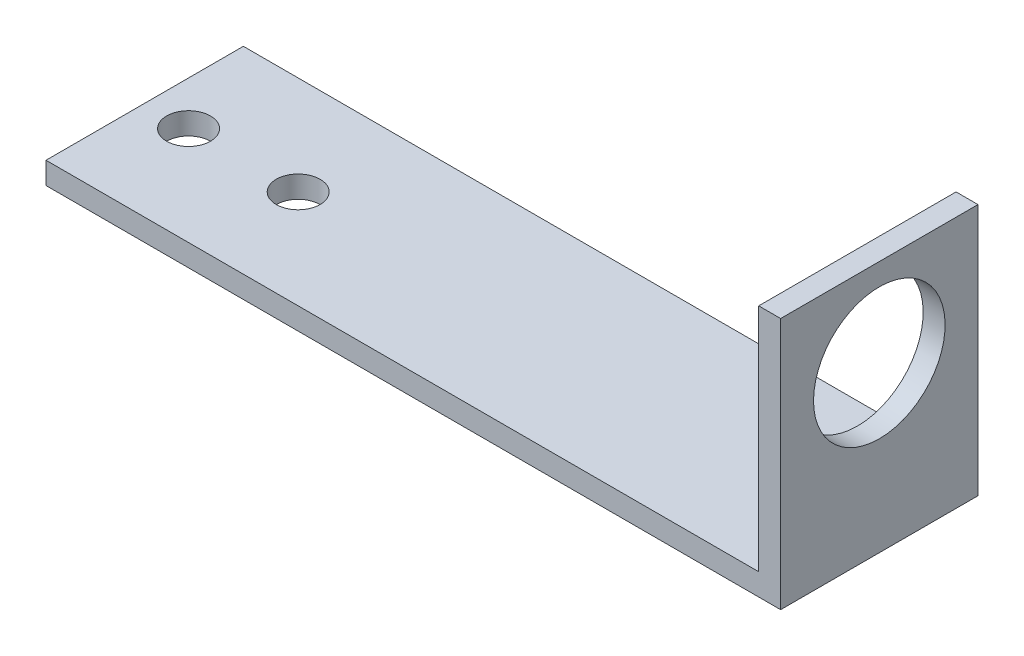
from build123d import *

# Parameters (mm, degrees)
BOSS_EXTRUDE1_DEPTH = 18
CUT_EXTRUDE1_REACH  = 4
SKETCH2_R           = 6
CUT_EXTRUDE2_REACH  = 4
SKETCH3_R           = 2


with BuildPart() as part:
    # Sketch1 → Boss-Extrude1 (new body)
    with BuildSketch(Plane.XY):
        Polygon((0, 0), (0, 23), (-2, 23), (-2, 2), (-67, 2), (-67, 0), align=None)
    extrude(amount=BOSS_EXTRUDE1_DEPTH)

    # Sketch2 → Cut-Extrude1 (cut, up to next)
    with BuildSketch(Plane.ZY.offset(2), mode=Mode.PRIVATE) as cut_extrude1_sk1:
        with Locations((9, 15)):
            Circle(SKETCH2_R)
    cut_extrude1_tool1 = extrude(cut_extrude1_sk1.sketch, amount=-CUT_EXTRUDE1_REACH, mode=Mode.PRIVATE) & part.part
    add(cut_extrude1_tool1.solids().sort_by_distance((-2, 15, 9))[0], mode=Mode.SUBTRACT)

    # Sketch3 → Cut-Extrude2 (cut, up to next)
    with BuildSketch(Plane(origin=(0, 2, 0), x_dir=(1, 0, 0), z_dir=(0, 1, 0)), mode=Mode.PRIVATE) as cut_extrude2_sk1:
        with Locations((-63, -9)):
            Circle(SKETCH3_R)
    cut_extrude2_tool1 = extrude(cut_extrude2_sk1.sketch, amount=-CUT_EXTRUDE2_REACH, mode=Mode.PRIVATE) & part.part
    add(cut_extrude2_tool1.solids().sort_by_distance((-63, 2, 9))[0], mode=Mode.SUBTRACT)
    # Sketch3 → Cut-Extrude2 (cut, up to next)
    with BuildSketch(Plane(origin=(0, 2, 0), x_dir=(1, 0, 0), z_dir=(0, 1, 0)), mode=Mode.PRIVATE) as cut_extrude2_sk2:
        with Locations((-53, -9)):
            Circle(SKETCH3_R)
    cut_extrude2_tool2 = extrude(cut_extrude2_sk2.sketch, amount=-CUT_EXTRUDE2_REACH, mode=Mode.PRIVATE) & part.part
    add(cut_extrude2_tool2.solids().sort_by_distance((-53, 2, 9))[0], mode=Mode.SUBTRACT)


solid = part.part
